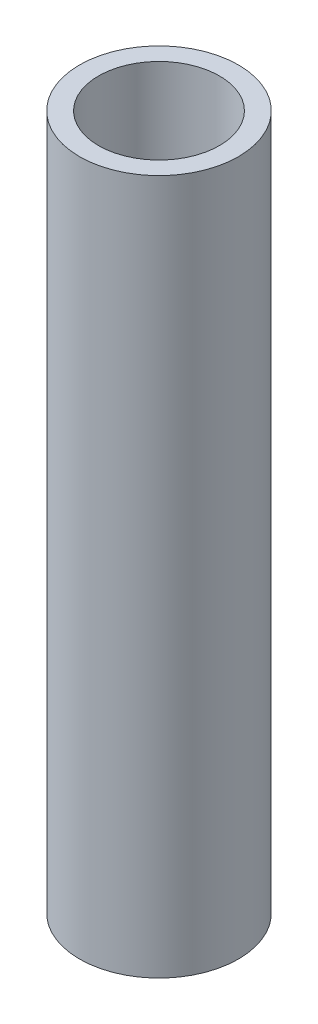
from build123d import *

# Parameters (mm, degrees)
SKETCH1_R           = 16.7005
SKETCH1_R_2         = 12.7
BOSS_EXTRUDE1_DEPTH = 146.05


with BuildPart() as part:
    # Sketch1 → Boss-Extrude1 (new body)
    with BuildSketch(Plane(origin=(0, 0, 0), x_dir=(1, 0, 0), z_dir=(0, 1, 0))):
        Circle(SKETCH1_R)
        Circle(SKETCH1_R_2, mode=Mode.SUBTRACT)
    extrude(amount=BOSS_EXTRUDE1_DEPTH)


solid = part.part
